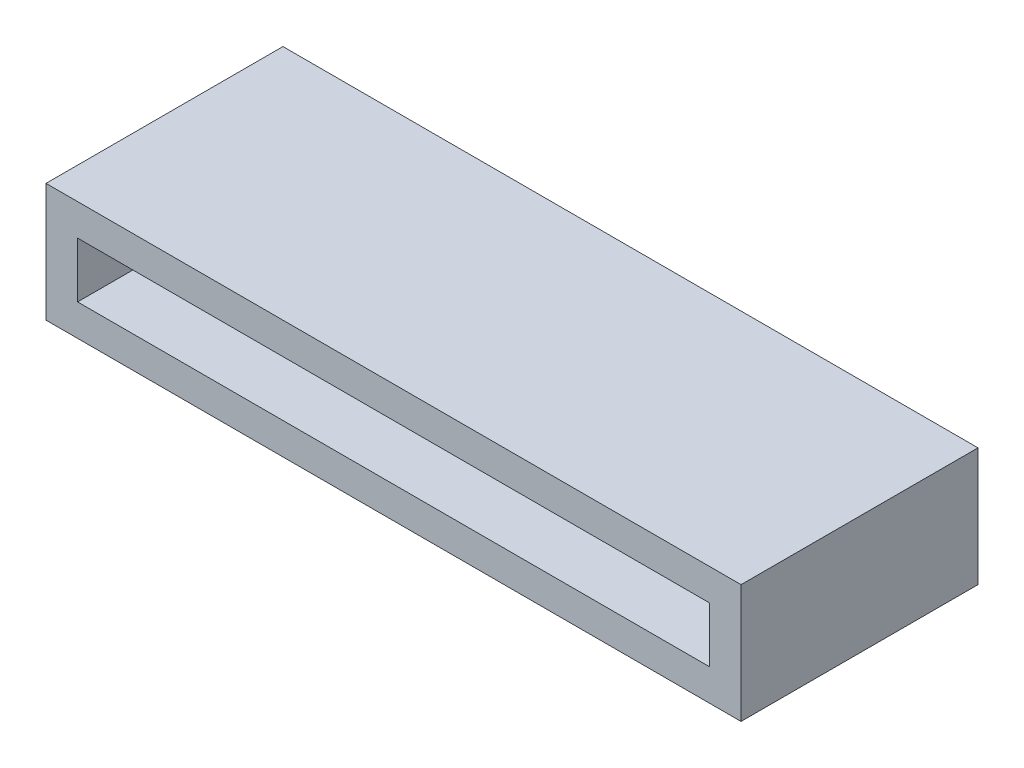
from build123d import *

# Parameters (mm, degrees)
SKETCH1_W           = 22
SKETCH1_H           = 3.75
BOSS_EXTRUDE1_DEPTH = 7.5
SHELL1_T            = -1


with BuildPart() as part:
    # Sketch1 → Boss-Extrude1 (new body)
    with BuildSketch(Plane.XY):
        Rectangle(SKETCH1_W, SKETCH1_H)
    extrude(amount=BOSS_EXTRUDE1_DEPTH)

    # Shell1
    shell1_openings = [part.faces().sort_by_distance(p)[0] for p in [
        (0, 0, 7.5),
    ]]
    offset(amount=SHELL1_T, openings=shell1_openings, kind=Kind.INTERSECTION)


solid = part.part
